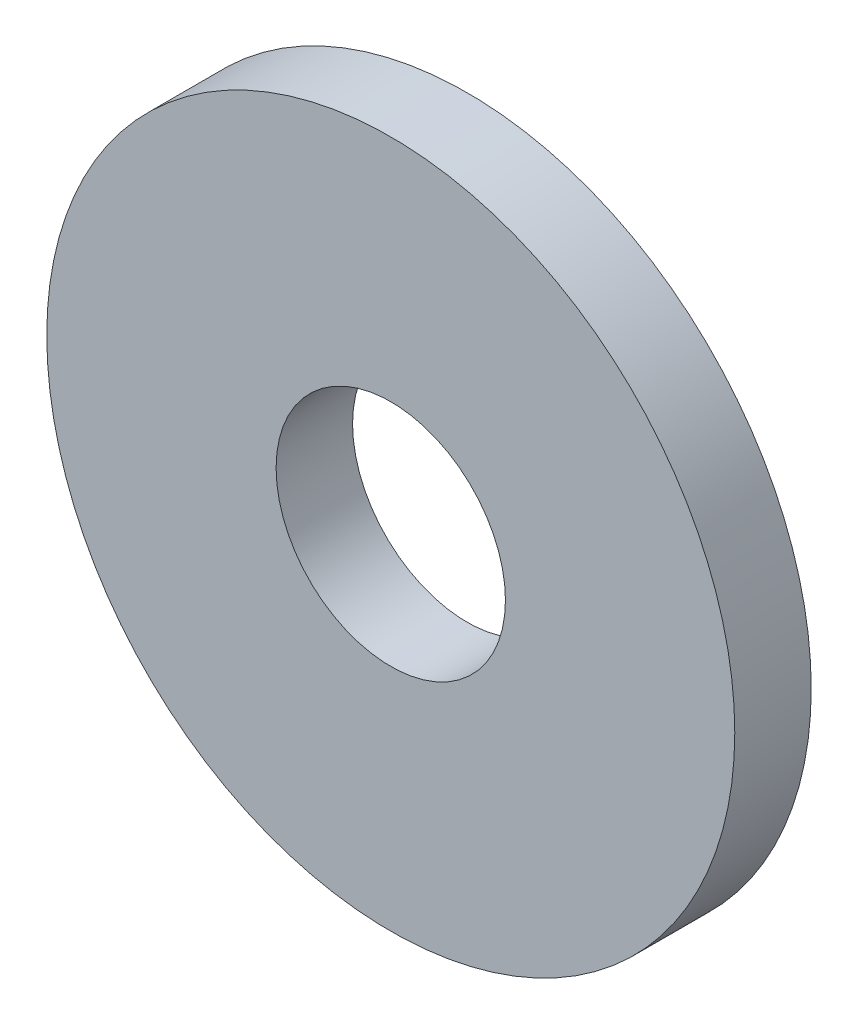
from build123d import *

# Parameters (mm, degrees)
SKETCH_1_R      = 4.5
SKETCH_1_R_2    = 1.5
EXTRUDE_1_DEPTH = 1


with BuildPart() as part:
    # 草图1 → 凸台-拉伸1 (new body)
    with BuildSketch(Plane.XY):
        Circle(SKETCH_1_R)
        Circle(SKETCH_1_R_2, mode=Mode.SUBTRACT)
    extrude(amount=EXTRUDE_1_DEPTH)


solid = part.part
